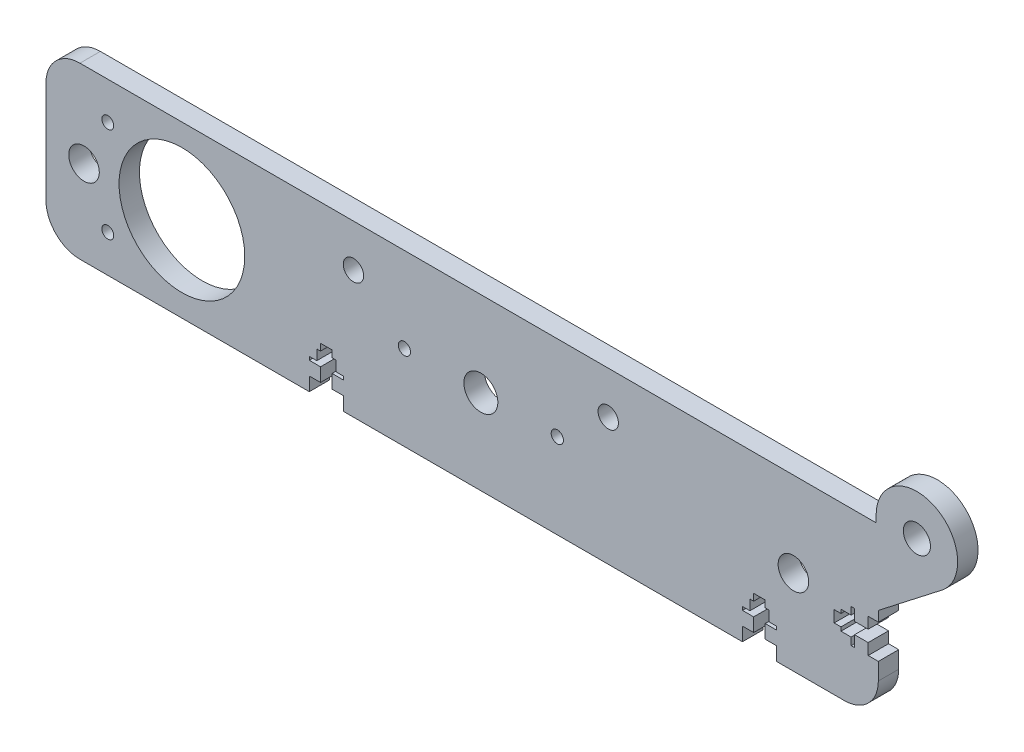
from build123d import *

# Parameters (mm, degrees)
ESBO_O1_R                = 18.5
ESBO_O1_R_2              = 4.5
ESBO_O1_R_3              = 4
ESBO_O1_R_4              = 5
ESBO_O1_R_5              = 1.8
ESBO_O1_R_6              = 3
ESBO_O1_R_7              = 1.75
RESSALTO_EXTRUS_O1_DEPTH = 6


with BuildPart() as part:
    # Esboço1 → Ressalto-extrusão1 (new body)
    with BuildSketch(Plane.XY):
        with BuildLine():
            Line((95, -25), (95, -21))
            Line((95, -21), (91.7, -21))
            Line((91.7, -21), (91.7, -17))
            Line((91.7, -17), (95, -17))
            Line((95, -17), (95, -16))
            Line((95, -16), (92.8, -16))
            Line((92.8, -16), (92.8, -13))
            Line((92.8, -13), (91.7, -13))
            Line((91.7, -13), (91.7, -11))
            Line((91.7, -11), (88.3, -11))
            Line((88.3, -11), (88.3, -13))
            Line((88.3, -13), (87.2, -13))
            Line((87.2, -13), (87.2, -16))
            Line((87.2, -16), (85, -16))
            Line((85, -16), (85, -17))
            Line((85, -17), (88.3, -17))
            Line((88.3, -17), (88.3, -21))
            Line((88.3, -21), (85, -21))
            Line((85, -21), (85, -25))
            Line((85, -25), (-32.5, -25))
            Line((-32.5, -25), (-32.5, -21))
            Line((-32.5, -21), (-35.8, -21))
            Line((-35.8, -21), (-35.8, -17))
            Line((-35.8, -17), (-32.5, -17))
            Line((-32.5, -17), (-32.5, -16))
            Line((-32.5, -16), (-34.7, -16))
            Line((-34.7, -16), (-34.7, -13))
            Line((-34.7, -13), (-35.8, -13))
            Line((-35.8, -13), (-35.8, -11))
            Line((-35.8, -11), (-39.2, -11))
            Line((-39.2, -11), (-39.2, -13))
            Line((-39.2, -13), (-40.3, -13))
            Line((-40.3, -13), (-40.3, -16))
            Line((-40.3, -16), (-42.5, -16))
            Line((-42.5, -16), (-42.5, -17))
            Line((-42.5, -17), (-39.2, -17))
            Line((-39.2, -17), (-39.2, -21))
            Line((-39.2, -21), (-42.5, -21))
            Line((-42.5, -21), (-42.5, -25))
            Line((-42.5, -25), (-110, -25))
            ThreePointArc((-110, -25), (-117.071067812, -22.071067812), (-120, -15))
            Line((-120, -15), (-120, 15))
            ThreePointArc((-120, 15), (-117.071067812, 22.071067812), (-110, 25))
            Line((-110, 25), (124.350151348, 25))
            Line((124.350151348, 25), (124.350151348, 27))
            ThreePointArc((124.350151348, 27), (141.627798395, 37.777125853), (143.707891624, 17.520355595))
            Line((143.707891624, 17.520355595), (125, 3))
            Line((125, 3), (125, 0))
            Line((125, 0), (122, 0))
            Line((122, 0), (122, -3.3))
            Line((122, -3.3), (118, -3.3))
            Line((118, -3.3), (118, 0))
            Line((118, 0), (117, 0))
            Line((117, 0), (117, -2.2))
            Line((117, -2.2), (114, -2.2))
            Line((114, -2.2), (114, -3.3))
            Line((114, -3.3), (112, -3.3))
            Line((112, -3.3), (112, -6.7))
            Line((112, -6.7), (114, -6.7))
            Line((114, -6.7), (114, -7.8))
            Line((114, -7.8), (117, -7.8))
            Line((117, -7.8), (117, -10))
            Line((117, -10), (118, -10))
            Line((118, -10), (118, -6.7))
            Line((118, -6.7), (122, -6.7))
            Line((122, -6.7), (122, -10))
            Line((122, -10), (125, -10))
            Line((125, -10), (125, -15))
            ThreePointArc((125, -15), (122.071067812, -22.071067812), (115, -25))
            Line((115, -25), (95, -25))
        make_face()
        with Locations((-80, 0)):
            Circle(ESBO_O1_R, mode=Mode.SUBTRACT)
        with Locations((100, 0)):
            Circle(ESBO_O1_R_2, mode=Mode.SUBTRACT)
        with Locations((136.350151348, 27)):
            Circle(ESBO_O1_R_3, mode=Mode.SUBTRACT)
        with Locations((8, 0)):
            Circle(ESBO_O1_R_4, mode=Mode.SUBTRACT)
        with Locations((-108.81, 0)):
            Circle(ESBO_O1_R_2, mode=Mode.SUBTRACT)
        with Locations((-14.5, 0)):
            Circle(ESBO_O1_R_5, mode=Mode.SUBTRACT)
        with Locations((30.5, 0)):
            Circle(ESBO_O1_R_5, mode=Mode.SUBTRACT)
        with Locations((-29.5, 12.5)):
            Circle(ESBO_O1_R_6, mode=Mode.SUBTRACT)
        with Locations((45.5, 12.5)):
            Circle(ESBO_O1_R_6, mode=Mode.SUBTRACT)
        with Locations((-101.81, 14)):
            Circle(ESBO_O1_R_7, mode=Mode.SUBTRACT)
        with Locations((-101.81, -14)):
            Circle(ESBO_O1_R_7, mode=Mode.SUBTRACT)
    extrude(amount=RESSALTO_EXTRUS_O1_DEPTH)


solid = part.part
